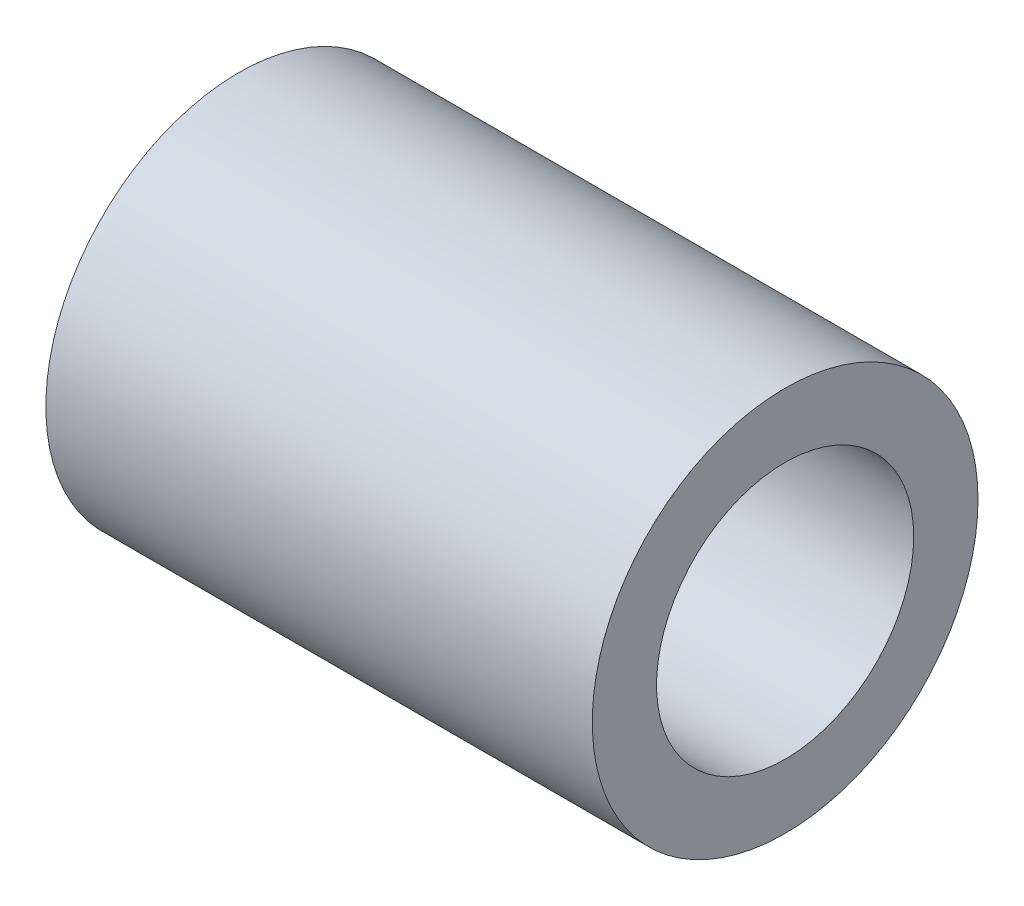
from build123d import *

# Parameters (mm, degrees)
CROQUIS1_R              = 6
CROQUIS1_R_2            = 4
SALIENTE_EXTRUIR1_DEPTH = 17


with BuildPart() as part:
    # Croquis1 → Saliente-Extruir1 (new body)
    with BuildSketch(Plane(origin=(0, 0, 0), x_dir=(0, 0, -1), z_dir=(1, 0, 0))):
        Circle(CROQUIS1_R)
        Circle(CROQUIS1_R_2, mode=Mode.SUBTRACT)
    extrude(amount=SALIENTE_EXTRUIR1_DEPTH)


solid = part.part
